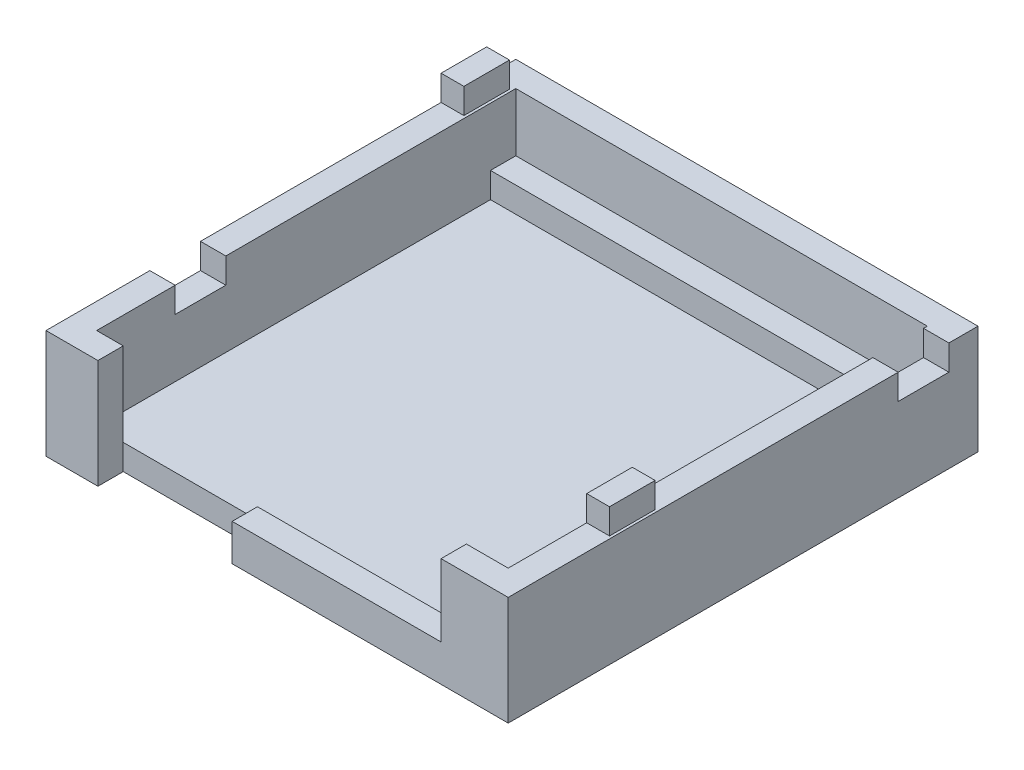
from build123d import *

# Parameters (mm, degrees)
SKETCH3_W            = 36.5
SKETCH3_H            = 37.1
SHELL_DEPTH          = 8.6
SKETCH4_W            = 32.5
SKETCH4_H            = 31.1
MAIN_CAVITY_DEPTH    = 6.6
SKETCH5_W            = 32.5
SKETCH5_H            = 2
SUPPORT_SHELF_DEPTH  = 4.6
TERMINAL_INPUT_DEPTH = 2
SKETCH7_W            = 1.8
SKETCH7_H            = 3.6
MALE_TABS_DEPTH      = 2
SKETCH8_W            = 2
SKETCH8_H            = 4
FEMALE_TABS_DEPTH    = 2


with BuildPart() as part:
    # Sketch3 → Shell (new body)
    with BuildSketch(Plane(origin=(0, 0, 0), x_dir=(1, 0, 0), z_dir=(0, 1, 0))):
        with Locations((18.25, -18.55)):
            Rectangle(SKETCH3_W, SKETCH3_H)
    extrude(amount=SHELL_DEPTH)

    # Sketch4 → Main Cavity (cut)
    with BuildSketch(Plane(origin=(0, 8.6, 0), x_dir=(1, 0, 0), z_dir=(0, 1, 0))):
        with Locations((18.25, -19.55)):
            Rectangle(SKETCH4_W, SKETCH4_H)
    extrude(amount=-MAIN_CAVITY_DEPTH, mode=Mode.SUBTRACT)

    # Sketch5 → Support Shelf (cut)
    with BuildSketch(Plane(origin=(0, 8.6, 0), x_dir=(1, 0, 0), z_dir=(0, 1, 0))):
        with Locations((18.25, -3)):
            Rectangle(SKETCH5_W, SKETCH5_H)
    extrude(amount=-SUPPORT_SHELF_DEPTH, mode=Mode.SUBTRACT)

    # Sketch6 → Terminal Input (cut)
    with BuildSketch(Plane.XY.offset(37.1)):
        Polygon((31.2, 2.9), (31.2, 8.6), (4.1, 8.6), (4.1, 0), (14.7, 0), (14.7, 2.9), align=None)
    extrude(amount=-TERMINAL_INPUT_DEPTH, mode=Mode.SUBTRACT)

    # Sketch7 → Male Tabs (add)
    with BuildSketch(Plane(origin=(0, 8.6, 0), x_dir=(1, 0, 0), z_dir=(0, 1, 0))):
        with Locations((35.4, -27.1)):
            Rectangle(SKETCH7_W, SKETCH7_H)
        with Locations((0.9, -4.1)):
            Rectangle(SKETCH7_W, SKETCH7_H)
    extrude(amount=MALE_TABS_DEPTH)

    # Sketch8 → Female Tabs (cut)
    with BuildSketch(Plane(origin=(0, 8.6, 0), x_dir=(1, 0, 0), z_dir=(0, 1, 0))):
        with Locations((35.5, -4.3)):
            Rectangle(SKETCH8_W, SKETCH8_H)
        with Locations((1, -26.9)):
            Rectangle(SKETCH8_W, SKETCH8_H)
    extrude(amount=-FEMALE_TABS_DEPTH, mode=Mode.SUBTRACT)


solid = part.part
